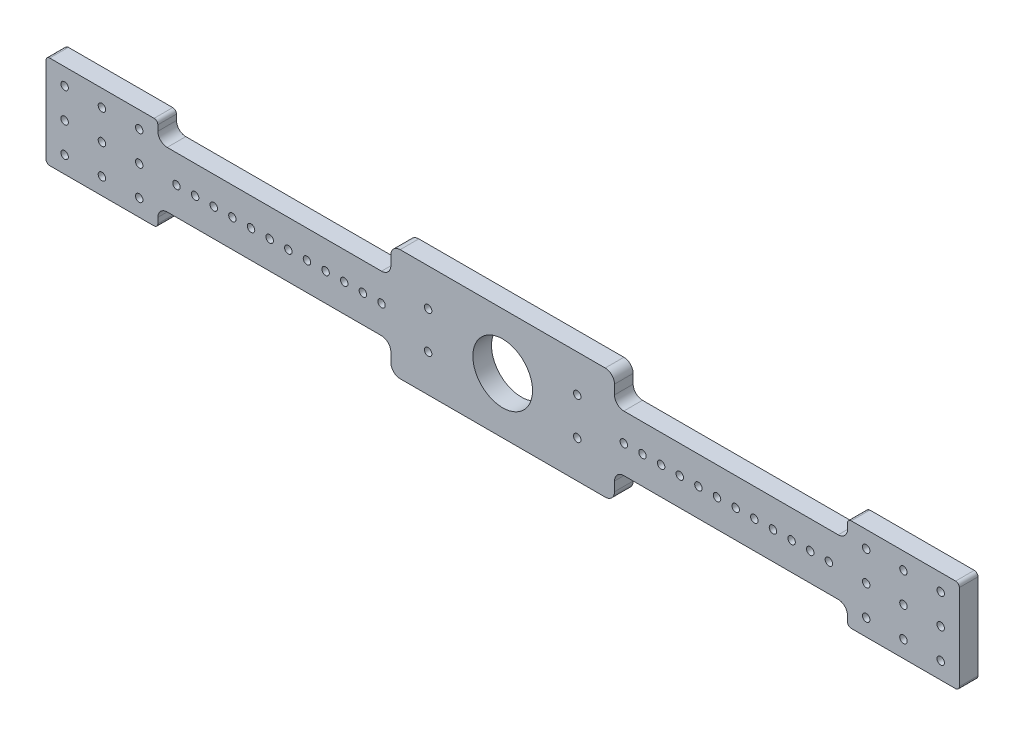
from build123d import *

# Parameters (mm, degrees)
BOSS_EXTRUDE1_DEPTH = 10
SKETCH2_R           = 2
SKETCH2_R_2         = 16
CUT_EXTRUDE1_DEPTH  = 11
FILLET1_R           = 5
SKETCH3_R           = 2
CUT_EXTRUDE2_DEPTH  = 11
SKETCH4_R           = 2
CUT_EXTRUDE3_DEPTH  = 11
LPATTERN1_COUNT     = 6
LPATTERN1_PITCH     = 10
LPATTERN1_COL_COUNT = 6
LPATTERN1_COL_PITCH = 10
SKETCH5_R           = 2
CUT_EXTRUDE4_DEPTH  = 11
FILLET2_R           = 2


with BuildPart() as part:
    # Sketch1 → Boss-Extrude1 (new body)
    with BuildSketch(Plane.XY):
        Polygon((245, 5), (245, 55), (185, 55), (185, 45), (60, 45), (60, 60), (-60, 60), (-60, 45), (-185, 45), (-185, 55), (-245, 55), (-245, 5), (-185, 5), (-185, 15), (-60, 15), (-60, 0), (60, 0), (60, 15), (185, 15), (185, 5), align=None)
    extrude(amount=BOSS_EXTRUDE1_DEPTH)

    # Sketch2 → Cut-Extrude1 (cut, through all)
    with BuildSketch(Plane.XY.offset(10)):
        with Locations((40, 20)):
            Circle(SKETCH2_R)
        with Locations((40, 40)):
            Circle(SKETCH2_R)
        with Locations((-40, 40)):
            Circle(SKETCH2_R)
        with Locations((-40, 20)):
            Circle(SKETCH2_R)
        with Locations((0, 30)):
            Circle(SKETCH2_R_2)
    extrude(amount=-CUT_EXTRUDE1_DEPTH, mode=Mode.SUBTRACT)

    # Fillet1
    fillet1_edges = [part.edges().sort_by_distance(p)[0] for p in [
        (185, 15, 5),
        (60, 15, 5),
        (60, 0, 5),
        (-60, 0, 5),
        (-60, 15, 5),
        (-185, 15, 5),
        (-185, 45, 5),
        (-60, 45, 5),
        (-60, 60, 5),
        (60, 60, 5),
        (60, 45, 5),
        (185, 45, 5),
    ]]
    fillet(fillet1_edges, radius=FILLET1_R)

    # Sketch3 → Cut-Extrude2 (cut, through all)
    with BuildSketch(Plane.XY.offset(10)):
        with Locations((-125, 30)):
            Circle(SKETCH3_R)
        with Locations((125, 30)):
            Circle(SKETCH3_R)
    cut_extrude2 = extrude(amount=-CUT_EXTRUDE2_DEPTH, mode=Mode.SUBTRACT)

    # Sketch4 → Cut-Extrude3 (cut, through all)
    with BuildSketch(Plane.XY.offset(10)):
        with Locations((-235, 14)):
            Circle(SKETCH4_R)
        with Locations((-215, 14)):
            Circle(SKETCH4_R)
        with Locations((-195, 14)):
            Circle(SKETCH4_R)
        with Locations((-195, 46)):
            Circle(SKETCH4_R)
        with Locations((-215, 46)):
            Circle(SKETCH4_R)
        with Locations((-235, 46)):
            Circle(SKETCH4_R)
        with Locations((235, 46)):
            Circle(SKETCH4_R)
        with Locations((215, 46)):
            Circle(SKETCH4_R)
        with Locations((195, 46)):
            Circle(SKETCH4_R)
        with Locations((195, 14)):
            Circle(SKETCH4_R)
        with Locations((215, 14)):
            Circle(SKETCH4_R)
        with Locations((235, 14)):
            Circle(SKETCH4_R)
        with Locations((-235, 30)):
            Circle(SKETCH4_R)
        with Locations((-215, 30)):
            Circle(SKETCH4_R)
        with Locations((-195, 30)):
            Circle(SKETCH4_R)
        with Locations((215, 30)):
            Circle(SKETCH4_R)
        with Locations((235, 30)):
            Circle(SKETCH4_R)
        with Locations((195, 30)):
            Circle(SKETCH4_R)
    extrude(amount=-CUT_EXTRUDE3_DEPTH, mode=Mode.SUBTRACT)

    # LPattern1: Cut-Extrude2 ×6
    with Locations(*[(-i * LPATTERN1_PITCH, 0, 0) for i in range(1, LPATTERN1_COUNT)]):
        add(cut_extrude2, mode=Mode.SUBTRACT)

    # LPattern1 col: Cut-Extrude2 ×6
    with Locations(*[(i * LPATTERN1_COL_PITCH, 0, 0) for i in range(1, LPATTERN1_COL_COUNT)]):
        add(cut_extrude2, mode=Mode.SUBTRACT)

    # Sketch5 → Cut-Extrude4 (cut, through all)
    with BuildSketch(Plane.XY.offset(10)):
        with Locations((-65, 30)):
            Circle(SKETCH5_R)
        with Locations((65, 30)):
            Circle(SKETCH5_R)
    extrude(amount=-CUT_EXTRUDE4_DEPTH, mode=Mode.SUBTRACT)

    # Fillet2
    fillet2_edges = [part.edges().sort_by_distance(p)[0] for p in [
        (245, 55, 5),
        (245, 5, 5),
        (185, 5, 5),
        (-185, 5, 5),
        (-245, 5, 5),
        (-245, 55, 5),
        (-185, 55, 5),
        (185, 55, 5),
    ]]
    fillet(fillet2_edges, radius=FILLET2_R)


solid = part.part
